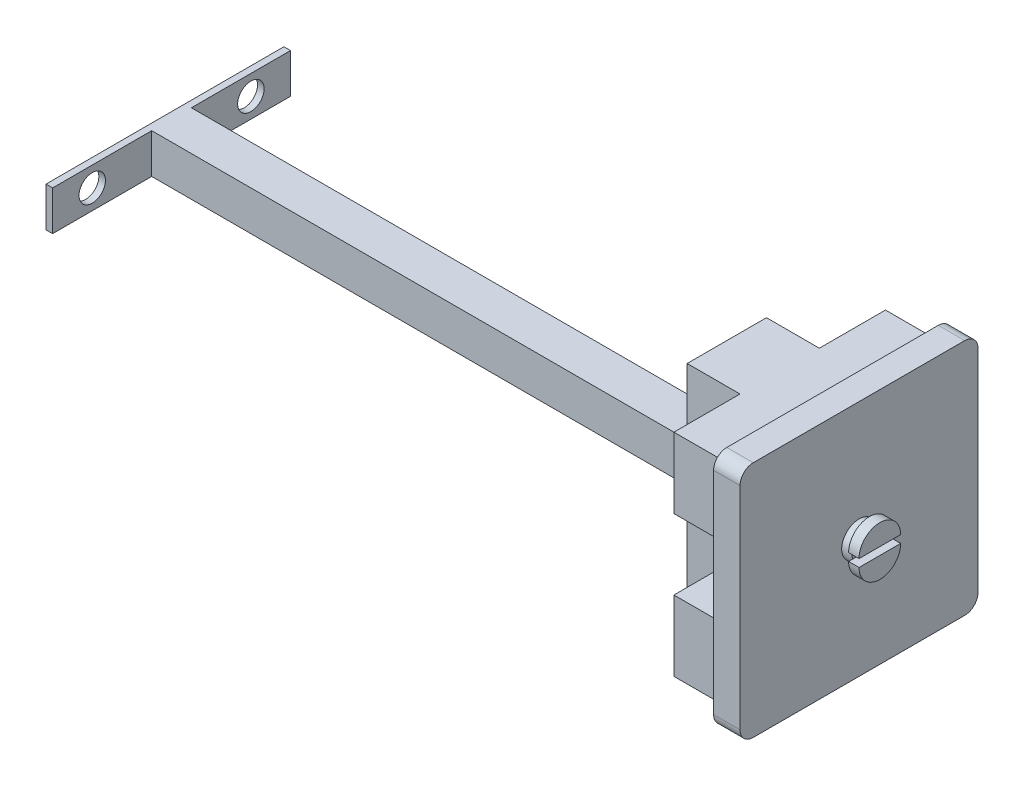
from build123d import *

# Parameters (mm, degrees)
SKETCH1_W           = 101.6
SKETCH1_H           = 19.05
BOSS_EXTRUDE1_DEPTH = 3.175
SKETCH2_W           = 19.05
SKETCH2_H           = 19.05
BOSS_EXTRUDE2_DEPTH = 266.7
SKETCH4_W           = 114.3
SKETCH4_H           = 114.3
BOSS_EXTRUDE3_DEPTH = 76.2
SKETCH5_W           = 25.4
SKETCH5_H           = 38.1
CUT_EXTRUDE2_DEPTH  = 150.368
SKETCH7_OUTSIDE_W   = 192.692
SKETCH7_OUTSIDE_H   = 192.692
SKETCH7_OUTSIDE_W_2 = 101.6
SKETCH7_OUTSIDE_H_2 = 101.6
CUT_EXTRUDE3_DEPTH  = 50.8
SKETCH8_W           = 25.4
SKETCH8_H           = 33.866666666
CUT_EXTRUDE4_DEPTH  = 140.208
SKETCH9_W           = 114.3
SKETCH9_H           = 114.3
CUT_EXTRUDE5_DEPTH  = 12.7
FILLET2_R           = 6.35
SKETCH10_R          = 6.35
CUT_EXTRUDE6_DEPTH  = 12.7
SCALE1_SCALE        = 0.06
MOVE_FACE1_BY       = 0.380000002
MOVE_FACE1_2_BY     = 0.380000002
SKETCH12_R          = 0.5
BOSS_EXTRUDE4_DEPTH = 0.3
BOSS_EXTRUDE5_DEPTH = 0.3


with BuildPart() as part:
    # Sketch1 → Boss-Extrude1 (new body)
    with BuildSketch(Plane(origin=(0, 0, 0), x_dir=(0, 0, -1), z_dir=(1, 0, 0))):
        Rectangle(SKETCH1_W, SKETCH1_H)
    extrude(amount=BOSS_EXTRUDE1_DEPTH)

    # Sketch2 → Boss-Extrude2 (add)
    with BuildSketch(Plane(origin=(3.175, 0, 0), x_dir=(0, 0, -1), z_dir=(1, 0, 0))):
        Rectangle(SKETCH2_W, SKETCH2_H)
    extrude(amount=BOSS_EXTRUDE2_DEPTH)

    # Sketch4 → Boss-Extrude3 (add)
    with BuildSketch(Plane(origin=(269.875, 0, 0), x_dir=(0, 0, -1), z_dir=(1, 0, 0))):
        Rectangle(SKETCH4_W, SKETCH4_H)
    extrude(amount=BOSS_EXTRUDE3_DEPTH)

    # Sketch5 → Cut-Extrude2 (cut)
    with BuildSketch(Plane.XZ.offset(57.15)):
        with Locations((282.575, 38.1)):
            Rectangle(SKETCH5_W, SKETCH5_H)
        with Locations((282.575, -38.1)):
            Rectangle(SKETCH5_W, SKETCH5_H)
    extrude(amount=-CUT_EXTRUDE2_DEPTH, mode=Mode.SUBTRACT)

    # Sketch7 outside → Cut-Extrude3 (cut)
    with BuildSketch(Plane.ZY.offset(-269.875)):
        Rectangle(SKETCH7_OUTSIDE_W, SKETCH7_OUTSIDE_H)
        Rectangle(SKETCH7_OUTSIDE_W_2, SKETCH7_OUTSIDE_H_2, mode=Mode.SUBTRACT)
    extrude(amount=-CUT_EXTRUDE3_DEPTH, mode=Mode.SUBTRACT)

    # Sketch8 → Cut-Extrude4 (cut)
    with BuildSketch(Plane.XY.offset(50.8)):
        with Locations((307.975, 0)):
            Rectangle(SKETCH8_W, SKETCH8_H)
    extrude(amount=-CUT_EXTRUDE4_DEPTH, mode=Mode.SUBTRACT)

    # Sketch9 → Cut-Extrude5 (cut)
    with BuildSketch(Plane(origin=(346.075, 0, 0), x_dir=(0, 0, -1), z_dir=(1, 0, 0))):
        Rectangle(SKETCH9_W, SKETCH9_H)
    extrude(amount=-CUT_EXTRUDE5_DEPTH, mode=Mode.SUBTRACT)

    # Fillet2
    fillet2_edges = [part.edges().sort_by_distance(p)[0] for p in [
        (327.025, -57.15, 57.15),
        (327.025, 57.15, 57.15),
        (327.025, -57.15, -57.15),
        (327.025, 57.15, -57.15),
    ]]
    fillet(fillet2_edges, radius=FILLET2_R)

    # Sketch10 → Cut-Extrude6 (cut)
    with BuildSketch(Plane.ZY):
        with Locations((-38.1, 0)):
            Circle(SKETCH10_R)
        with Locations((38.1, 0)):
            Circle(SKETCH10_R)
    extrude(amount=-CUT_EXTRUDE6_DEPTH, mode=Mode.SUBTRACT)


with BuildPart() as part_1:
    # Scale1: scaled about (275.471689012, 0, 0)
    add(part.part.scale(SCALE1_SCALE).moved(Location((258.943387671, 0, 0))))

    # Move Face1: a face moved outward by 0.38
    extrude(part_1.faces().sort_by_distance((259.038637671, 0, -3.048))[0], amount=MOVE_FACE1_BY, dir=(0, 0, -1))

    # Move Face1 2: a face moved outward by 0.38
    extrude(part_1.faces().sort_by_distance((259.038637671, 0, 3.048))[0], amount=MOVE_FACE1_2_BY, dir=(0, 0, 1))

    # Sketch12 → Boss-Extrude4 (add)
    with BuildSketch(Plane(origin=(278.945887671, 0, 0), x_dir=(0, 0, -1), z_dir=(1, 0, 0))):
        Circle(SKETCH12_R)
    extrude(amount=BOSS_EXTRUDE4_DEPTH)

    # Sketch13 → Boss-Extrude5 (add)
    with BuildSketch(Plane(origin=(279.245887671, 0, 0), x_dir=(0, 0, -1), z_dir=(1, 0, 0))):
        with BuildLine():
            Line((0.6, 0.11), (-0.6, 0.11))
            ThreePointArc((-0.6, 0.11), (0, 0.71), (0.6, 0.11))
        make_face()
        with BuildLine():
            Line((0.6, -0.11), (-0.6, -0.11))
            ThreePointArc((-0.6, -0.11), (0, -0.71), (0.6, -0.11))
        make_face()
    extrude(amount=BOSS_EXTRUDE5_DEPTH)


solid = part_1.part
